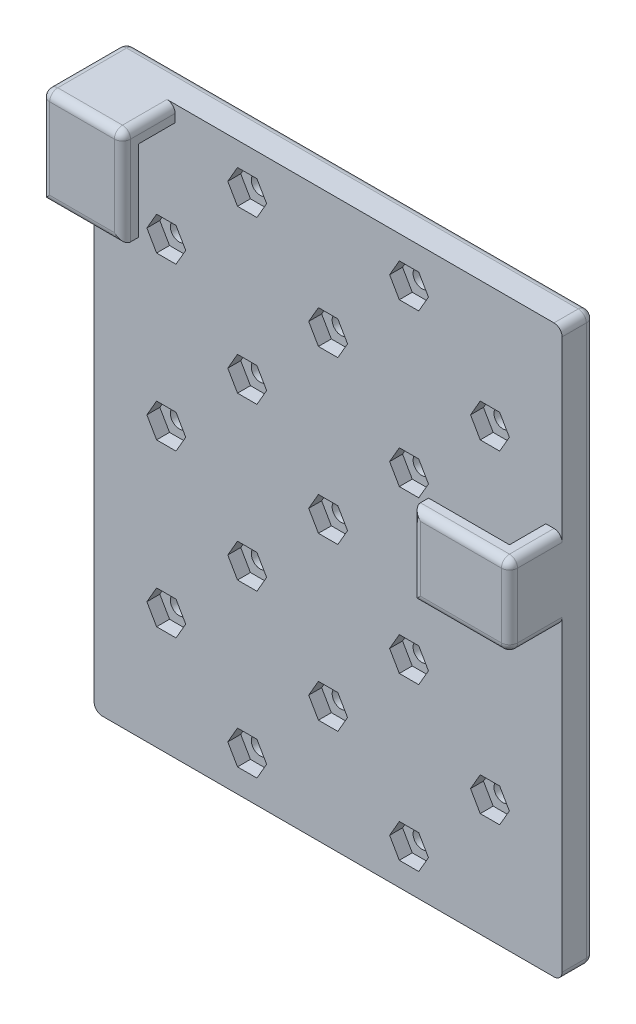
from build123d import *

# Parameters (mm, degrees)
BOSS_EXTRU_1_DEPTH      = 10
BOSS_EXTRU_2_DEPTH      = 10
ESQUISSE5_W             = 57.832159566
ESQUISSE5_H             = 70
BOSS_EXTRU_3_DEPTH      = 2
BOSS_EXTRU_3_DEPTH_BACK = 2
ENL_V_MAT_EXTRU_1_REACH = 12.5
ESQUISSE6_R             = 1.1
ENL_V_MAT_EXTRU_2_DEPTH = 1.6
CONG_2_R                = 1


with BuildPart() as part:
    # Esquisse1 → Boss.-Extru.1 (new body)
    with BuildSketch(Plane(origin=(0, 0, 0), x_dir=(1, 0, 0), z_dir=(0, 1, 0))):
        Polygon((19.832159566, -6.5), (31.832159566, -6.5), (31.832159566, 2), (-26, 2), (-26, 0), (29.832159566, 0), (29.832159566, -4.5), (19.832159566, -4.5), align=None)
    extrude(amount=BOSS_EXTRU_1_DEPTH)

    # Esquisse4 → Boss.-Extru.2 (add)
    with BuildSketch(Plane.ZY.offset(26)):
        Polygon((-2, 10), (0, 10), (0, 30), (4.5, 30), (4.5, 20), (6.5, 20), (6.5, 32), (-2, 32), align=None)
    extrude(amount=-BOSS_EXTRU_2_DEPTH)

    # Esquisse5 → Boss.-Extru.3 (add, two sides)
    with BuildSketch(Plane(origin=(0, 0, -2), x_dir=(-1, 0, 0), z_dir=(0, 0, -1))) as boss_extru_3_sk:
        with Locations((-2.916079783, -3)):
            Rectangle(ESQUISSE5_W, ESQUISSE5_H)
    extrude(amount=BOSS_EXTRU_3_DEPTH)
    extrude(boss_extru_3_sk.sketch, amount=-BOSS_EXTRU_3_DEPTH_BACK)

    # Esquisse6 → Enlèv. mat.-Extru.1 (cut, up to next)
    with BuildSketch(Plane(origin=(0, 0, -4), x_dir=(-1, 0, 0), z_dir=(0, 0, -1)), mode=Mode.PRIVATE) as enl_v_mat_extru_1_sk1:
        with Locations((7.083920217, 27)):
            Circle(ESQUISSE6_R)
    enl_v_mat_extru_1_tool1 = extrude(enl_v_mat_extru_1_sk1.sketch, amount=-ENL_V_MAT_EXTRU_1_REACH, mode=Mode.PRIVATE) & part.part
    add(enl_v_mat_extru_1_tool1.solids().sort_by_distance((-7.08392, 27, -4))[0], mode=Mode.SUBTRACT)
    # Esquisse6 → Enlèv. mat.-Extru.1 (cut, up to next)
    with BuildSketch(Plane(origin=(0, 0, -4), x_dir=(-1, 0, 0), z_dir=(0, 0, -1)), mode=Mode.PRIVATE) as enl_v_mat_extru_1_sk2:
        with Locations((17.083920217, -3)):
            Circle(ESQUISSE6_R)
    enl_v_mat_extru_1_tool2 = extrude(enl_v_mat_extru_1_sk2.sketch, amount=-ENL_V_MAT_EXTRU_1_REACH, mode=Mode.PRIVATE) & part.part
    add(enl_v_mat_extru_1_tool2.solids().sort_by_distance((-17.08392, -3, -4))[0], mode=Mode.SUBTRACT)
    # Esquisse6 → Enlèv. mat.-Extru.1 (cut, up to next)
    with BuildSketch(Plane(origin=(0, 0, -4), x_dir=(-1, 0, 0), z_dir=(0, 0, -1)), mode=Mode.PRIVATE) as enl_v_mat_extru_1_sk3:
        with Locations((7.083920217, -33)):
            Circle(ESQUISSE6_R)
    enl_v_mat_extru_1_tool3 = extrude(enl_v_mat_extru_1_sk3.sketch, amount=-ENL_V_MAT_EXTRU_1_REACH, mode=Mode.PRIVATE) & part.part
    add(enl_v_mat_extru_1_tool3.solids().sort_by_distance((-7.08392, -33, -4))[0], mode=Mode.SUBTRACT)
    # Esquisse6 → Enlèv. mat.-Extru.1 (cut, up to next)
    with BuildSketch(Plane(origin=(0, 0, -4), x_dir=(-1, 0, 0), z_dir=(0, 0, -1)), mode=Mode.PRIVATE) as enl_v_mat_extru_1_sk4:
        with Locations((-22.916079783, 17)):
            Circle(ESQUISSE6_R)
    enl_v_mat_extru_1_tool4 = extrude(enl_v_mat_extru_1_sk4.sketch, amount=-ENL_V_MAT_EXTRU_1_REACH, mode=Mode.PRIVATE) & part.part
    add(enl_v_mat_extru_1_tool4.solids().sort_by_distance((22.91608, 17, -4))[0], mode=Mode.SUBTRACT)
    # Esquisse6 → Enlèv. mat.-Extru.1 (cut, up to next)
    with BuildSketch(Plane(origin=(0, 0, -4), x_dir=(-1, 0, 0), z_dir=(0, 0, -1)), mode=Mode.PRIVATE) as enl_v_mat_extru_1_sk5:
        with Locations((17.083920217, 17)):
            Circle(ESQUISSE6_R)
    enl_v_mat_extru_1_tool5 = extrude(enl_v_mat_extru_1_sk5.sketch, amount=-ENL_V_MAT_EXTRU_1_REACH, mode=Mode.PRIVATE) & part.part
    add(enl_v_mat_extru_1_tool5.solids().sort_by_distance((-17.08392, 17, -4))[0], mode=Mode.SUBTRACT)
    # Esquisse6 → Enlèv. mat.-Extru.1 (cut, up to next)
    with BuildSketch(Plane(origin=(0, 0, -4), x_dir=(-1, 0, 0), z_dir=(0, 0, -1)), mode=Mode.PRIVATE) as enl_v_mat_extru_1_sk6:
        with Locations((17.083920217, -23)):
            Circle(ESQUISSE6_R)
    enl_v_mat_extru_1_tool6 = extrude(enl_v_mat_extru_1_sk6.sketch, amount=-ENL_V_MAT_EXTRU_1_REACH, mode=Mode.PRIVATE) & part.part
    add(enl_v_mat_extru_1_tool6.solids().sort_by_distance((-17.08392, -23, -4))[0], mode=Mode.SUBTRACT)
    # Esquisse6 → Enlèv. mat.-Extru.1 (cut, up to next)
    with BuildSketch(Plane(origin=(0, 0, -4), x_dir=(-1, 0, 0), z_dir=(0, 0, -1)), mode=Mode.PRIVATE) as enl_v_mat_extru_1_sk7:
        with Locations((-12.916079783, 27)):
            Circle(ESQUISSE6_R)
    enl_v_mat_extru_1_tool7 = extrude(enl_v_mat_extru_1_sk7.sketch, amount=-ENL_V_MAT_EXTRU_1_REACH, mode=Mode.PRIVATE) & part.part
    add(enl_v_mat_extru_1_tool7.solids().sort_by_distance((12.91608, 27, -4))[0], mode=Mode.SUBTRACT)
    # Esquisse6 → Enlèv. mat.-Extru.1 (cut, up to next)
    with BuildSketch(Plane(origin=(0, 0, -4), x_dir=(-1, 0, 0), z_dir=(0, 0, -1)), mode=Mode.PRIVATE) as enl_v_mat_extru_1_sk8:
        with Locations((-12.916079783, -33)):
            Circle(ESQUISSE6_R)
    enl_v_mat_extru_1_tool8 = extrude(enl_v_mat_extru_1_sk8.sketch, amount=-ENL_V_MAT_EXTRU_1_REACH, mode=Mode.PRIVATE) & part.part
    add(enl_v_mat_extru_1_tool8.solids().sort_by_distance((12.91608, -33, -4))[0], mode=Mode.SUBTRACT)
    # Esquisse6 → Enlèv. mat.-Extru.1 (cut, up to next)
    with BuildSketch(Plane(origin=(0, 0, -4), x_dir=(-1, 0, 0), z_dir=(0, 0, -1)), mode=Mode.PRIVATE) as enl_v_mat_extru_1_sk9:
        with Locations((-22.916079783, -3)):
            Circle(ESQUISSE6_R)
    enl_v_mat_extru_1_tool9 = extrude(enl_v_mat_extru_1_sk9.sketch, amount=-ENL_V_MAT_EXTRU_1_REACH, mode=Mode.PRIVATE) & part.part
    add(enl_v_mat_extru_1_tool9.solids().sort_by_distance((22.91608, -3, -4))[0], mode=Mode.SUBTRACT)
    # Esquisse6 → Enlèv. mat.-Extru.1 (cut, up to next)
    with BuildSketch(Plane(origin=(0, 0, -4), x_dir=(-1, 0, 0), z_dir=(0, 0, -1)), mode=Mode.PRIVATE) as enl_v_mat_extru_1_sk10:
        with Locations((-22.916079783, -23)):
            Circle(ESQUISSE6_R)
    enl_v_mat_extru_1_tool10 = extrude(enl_v_mat_extru_1_sk10.sketch, amount=-ENL_V_MAT_EXTRU_1_REACH, mode=Mode.PRIVATE) & part.part
    add(enl_v_mat_extru_1_tool10.solids().sort_by_distance((22.91608, -23, -4))[0], mode=Mode.SUBTRACT)
    # Esquisse6 → Enlèv. mat.-Extru.1 (cut, up to next)
    with BuildSketch(Plane(origin=(0, 0, -4), x_dir=(-1, 0, 0), z_dir=(0, 0, -1)), mode=Mode.PRIVATE) as enl_v_mat_extru_1_sk11:
        with Locations((7.083920217, -13)):
            Circle(ESQUISSE6_R)
    enl_v_mat_extru_1_tool11 = extrude(enl_v_mat_extru_1_sk11.sketch, amount=-ENL_V_MAT_EXTRU_1_REACH, mode=Mode.PRIVATE) & part.part
    add(enl_v_mat_extru_1_tool11.solids().sort_by_distance((-7.08392, -13, -4))[0], mode=Mode.SUBTRACT)
    # Esquisse6 → Enlèv. mat.-Extru.1 (cut, up to next)
    with BuildSketch(Plane(origin=(0, 0, -4), x_dir=(-1, 0, 0), z_dir=(0, 0, -1)), mode=Mode.PRIVATE) as enl_v_mat_extru_1_sk12:
        with Locations((7.083920217, 7)):
            Circle(ESQUISSE6_R)
    enl_v_mat_extru_1_tool12 = extrude(enl_v_mat_extru_1_sk12.sketch, amount=-ENL_V_MAT_EXTRU_1_REACH, mode=Mode.PRIVATE) & part.part
    add(enl_v_mat_extru_1_tool12.solids().sort_by_distance((-7.08392, 7, -4))[0], mode=Mode.SUBTRACT)
    # Esquisse6 → Enlèv. mat.-Extru.1 (cut, up to next)
    with BuildSketch(Plane(origin=(0, 0, -4), x_dir=(-1, 0, 0), z_dir=(0, 0, -1)), mode=Mode.PRIVATE) as enl_v_mat_extru_1_sk13:
        with Locations((-2.916079783, -23)):
            Circle(ESQUISSE6_R)
    enl_v_mat_extru_1_tool13 = extrude(enl_v_mat_extru_1_sk13.sketch, amount=-ENL_V_MAT_EXTRU_1_REACH, mode=Mode.PRIVATE) & part.part
    add(enl_v_mat_extru_1_tool13.solids().sort_by_distance((2.91608, -23, -4))[0], mode=Mode.SUBTRACT)
    # Esquisse6 → Enlèv. mat.-Extru.1 (cut, up to next)
    with BuildSketch(Plane(origin=(0, 0, -4), x_dir=(-1, 0, 0), z_dir=(0, 0, -1)), mode=Mode.PRIVATE) as enl_v_mat_extru_1_sk14:
        with Locations((-2.916079783, -3)):
            Circle(ESQUISSE6_R)
    enl_v_mat_extru_1_tool14 = extrude(enl_v_mat_extru_1_sk14.sketch, amount=-ENL_V_MAT_EXTRU_1_REACH, mode=Mode.PRIVATE) & part.part
    add(enl_v_mat_extru_1_tool14.solids().sort_by_distance((2.91608, -3, -4))[0], mode=Mode.SUBTRACT)
    # Esquisse6 → Enlèv. mat.-Extru.1 (cut, up to next)
    with BuildSketch(Plane(origin=(0, 0, -4), x_dir=(-1, 0, 0), z_dir=(0, 0, -1)), mode=Mode.PRIVATE) as enl_v_mat_extru_1_sk15:
        with Locations((-2.916079783, 17)):
            Circle(ESQUISSE6_R)
    enl_v_mat_extru_1_tool15 = extrude(enl_v_mat_extru_1_sk15.sketch, amount=-ENL_V_MAT_EXTRU_1_REACH, mode=Mode.PRIVATE) & part.part
    add(enl_v_mat_extru_1_tool15.solids().sort_by_distance((2.91608, 17, -4))[0], mode=Mode.SUBTRACT)
    # Esquisse6 → Enlèv. mat.-Extru.1 (cut, up to next)
    with BuildSketch(Plane(origin=(0, 0, -4), x_dir=(-1, 0, 0), z_dir=(0, 0, -1)), mode=Mode.PRIVATE) as enl_v_mat_extru_1_sk16:
        with Locations((-12.916079783, 7)):
            Circle(ESQUISSE6_R)
    enl_v_mat_extru_1_tool16 = extrude(enl_v_mat_extru_1_sk16.sketch, amount=-ENL_V_MAT_EXTRU_1_REACH, mode=Mode.PRIVATE) & part.part
    add(enl_v_mat_extru_1_tool16.solids().sort_by_distance((12.91608, 7, -4))[0], mode=Mode.SUBTRACT)
    # Esquisse6 → Enlèv. mat.-Extru.1 (cut, up to next)
    with BuildSketch(Plane(origin=(0, 0, -4), x_dir=(-1, 0, 0), z_dir=(0, 0, -1)), mode=Mode.PRIVATE) as enl_v_mat_extru_1_sk17:
        with Locations((-12.916079783, -13)):
            Circle(ESQUISSE6_R)
    enl_v_mat_extru_1_tool17 = extrude(enl_v_mat_extru_1_sk17.sketch, amount=-ENL_V_MAT_EXTRU_1_REACH, mode=Mode.PRIVATE) & part.part
    add(enl_v_mat_extru_1_tool17.solids().sort_by_distance((12.91608, -13, -4))[0], mode=Mode.SUBTRACT)

    # Esquisse7 → Enlèv. mat.-Extru.2 (cut)
    with BuildSketch(Plane.XY):
        Polygon((11.716079783, 24.921539031), (14.116079783, 24.921539031), (15.316079783, 27), (14.116079783, 29.078460969), (11.716079783, 29.078460969), (10.516079783, 27), align=None)
        Polygon((-5.883920217, 24.921539031), (-4.683920217, 27), (-5.883920217, 29.078460969), (-8.283920217, 29.078460969), (-9.483920217, 27), (-8.283920217, 24.921539031), align=None)
        Polygon((-15.883920217, 14.921539031), (-14.683920217, 17), (-15.883920217, 19.078460969), (-18.283920217, 19.078460969), (-19.483920217, 17), (-18.283920217, 14.921539031), align=None)
        Polygon((24.116079783, 14.921539031), (25.316079783, 17), (24.116079783, 19.078460969), (21.716079783, 19.078460969), (20.516079783, 17), (21.716079783, 14.921539031), align=None)
        Polygon((24.116079783, -5.078460969), (25.316079783, -3), (24.116079783, -0.921539031), (21.716079783, -0.921539031), (20.516079783, -3), (21.716079783, -5.078460969), align=None)
        Polygon((-15.883920217, -5.078460969), (-14.683920217, -3), (-15.883920217, -0.921539031), (-18.283920217, -0.921539031), (-19.483920217, -3), (-18.283920217, -5.078460969), align=None)
        Polygon((24.116079783, -25.078460969), (25.316079783, -23), (24.116079783, -20.921539031), (21.716079783, -20.921539031), (20.516079783, -23), (21.716079783, -25.078460969), align=None)
        Polygon((14.116079783, -35.078460969), (15.316079783, -33), (14.116079783, -30.921539031), (11.716079783, -30.921539031), (10.516079783, -33), (11.716079783, -35.078460969), align=None)
        Polygon((-5.883920217, -35.078460969), (-4.683920217, -33), (-5.883920217, -30.921539031), (-8.283920217, -30.921539031), (-9.483920217, -33), (-8.283920217, -35.078460969), align=None)
        Polygon((-15.883920217, -25.078460969), (-14.683920217, -23), (-15.883920217, -20.921539031), (-18.283920217, -20.921539031), (-19.483920217, -23), (-18.283920217, -25.078460969), align=None)
        Polygon((4.116079783, 14.921539031), (5.316079783, 17), (4.116079783, 19.078460969), (1.716079783, 19.078460969), (0.516079783, 17), (1.716079783, 14.921539031), align=None)
        Polygon((14.116079783, 4.921539031), (15.316079783, 7), (14.116079783, 9.078460969), (11.716079783, 9.078460969), (10.516079783, 7), (11.716079783, 4.921539031), align=None)
        Polygon((-5.883920217, 4.921539031), (-4.683920217, 7), (-5.883920217, 9.078460969), (-8.283920217, 9.078460969), (-9.483920217, 7), (-8.283920217, 4.921539031), align=None)
        Polygon((4.116079783, -5.078460969), (5.316079783, -3), (4.116079783, -0.921539031), (1.716079783, -0.921539031), (0.516079783, -3), (1.716079783, -5.078460969), align=None)
        Polygon((-5.883920217, -15.078460969), (-4.683920217, -13), (-5.883920217, -10.921539031), (-8.283920217, -10.921539031), (-9.483920217, -13), (-8.283920217, -15.078460969), align=None)
        Polygon((4.116079783, -25.078460969), (5.316079783, -23), (4.116079783, -20.921539031), (1.716079783, -20.921539031), (0.516079783, -23), (1.716079783, -25.078460969), align=None)
        Polygon((14.116079783, -15.078460969), (15.316079783, -13), (14.116079783, -10.921539031), (11.716079783, -10.921539031), (10.516079783, -13), (11.716079783, -15.078460969), align=None)
    extrude(amount=-ENL_V_MAT_EXTRU_2_DEPTH, mode=Mode.SUBTRACT)

    # Congé2
    cong_2_edges = [part.edges().sort_by_distance(p)[0] for p in [
        (31.832159566, 0, 3.25),
        (25.832159566, 0, 6.5),
        (31.832159566, 10, 3.25),
        (31.832159566, 5, 6.5),
        (19.832159566, 5, 6.5),
        (-16, 32, 3.25),
        (-16, 26, 6.5),
        (-21, 32, 6.5),
        (-21, 20, 6.5),
        (-26, 26, 6.5),
        (-26, 32, 1.25),
        (31.832159566, -38, -2),
        (31.832159566, 32, -2),
        (-26, -38, -2),
        (-26, -3, -4),
        (2.916079783, 32, -4),
        (31.832159566, -3, -4),
        (2.916079783, -38, -4),
        (25.832159566, 10, 6.5),
    ]]
    fillet(cong_2_edges, radius=CONG_2_R)


solid = part.part
